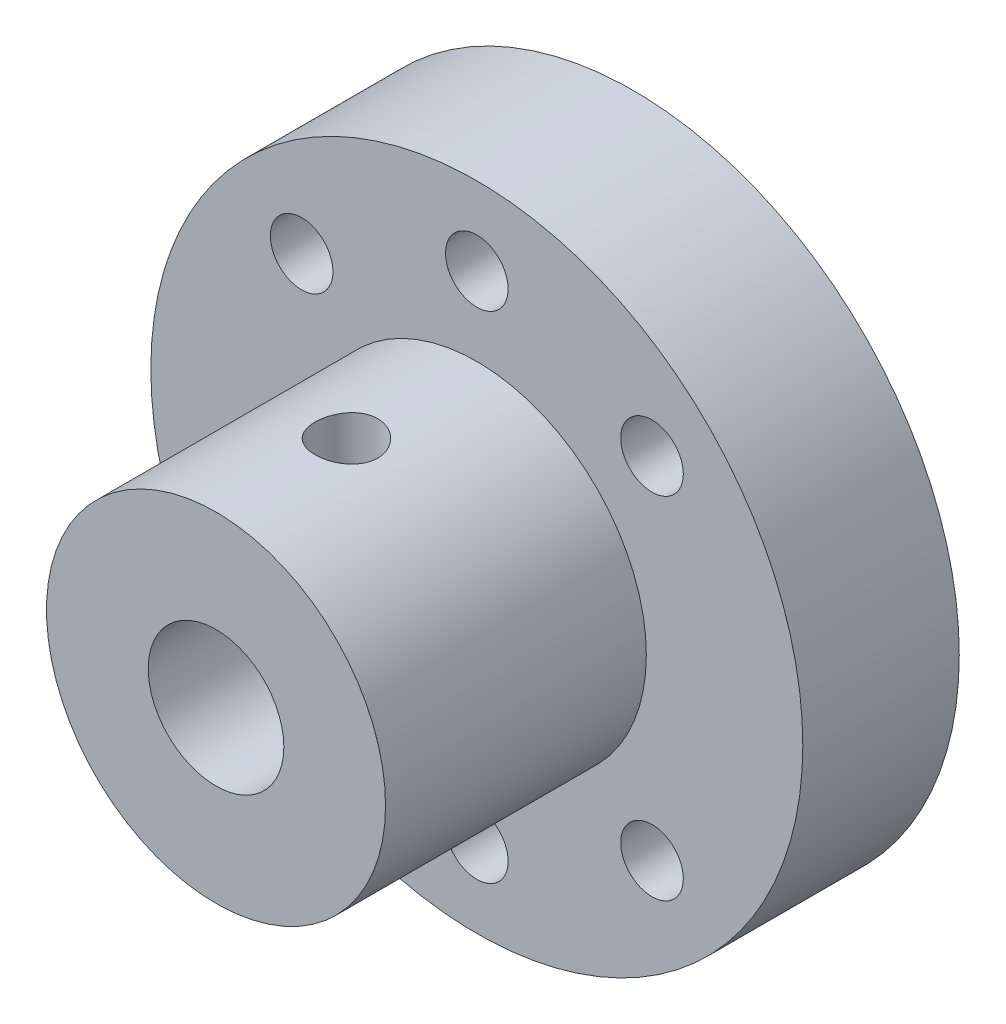
from build123d import *

# Parameters (mm, degrees)
SKETCH2_R               = 12.5
BOSS_EXTRUDE1_DEPTH     = 6
SKETCH3_R               = 6.5
SKETCH3_R_2             = 2.5
BOSS_EXTRUDE2_DEPTH     = 10
CUT_EXTRUDE1_DEPTH      = 25
CUT_EXTRUDE1_DEPTH_BACK = 25
SKETCH4_R               = 1.2
SKETCH5_R               = 1.2
CUT_EXTRUDE2_DEPTH      = 25
CIRPATTERN1_COUNT       = 2
CIRPATTERN1_ANGLE       = 45
CUT_EXTRUDE3_DEPTH      = 50
CUT_EXTRUDE3_DEPTH_BACK = 20
SKETCH6_R               = 2.6
CIRPATTERN2_COUNT       = 2
CIRPATTERN2_ANGLE       = 315
MIRROR1_COPY_1_SKETCH_R = 1.2
MIRROR1_COPY_1_DEPTH    = 25
MIRROR1_COPY_2_SKETCH_R = 1.2
MIRROR1_COPY_2_DEPTH    = 25
MIRROR1_COPY_3_SKETCH_R = 1.2
MIRROR1_COPY_3_DEPTH    = 25
MIRROR1_COPY_4_SKETCH_R = 1.2
MIRROR1_COPY_4_DEPTH    = 25


with BuildPart() as part:
    # Sketch2 → Boss-Extrude1 (new body)
    with BuildSketch(Plane.XY):
        Circle(SKETCH2_R)
    extrude(amount=BOSS_EXTRUDE1_DEPTH)

    # Sketch3 → Boss-Extrude2 (add)
    with BuildSketch(Plane.XY.offset(6)):
        Circle(SKETCH3_R)
        Circle(SKETCH3_R_2, mode=Mode.SUBTRACT)
    extrude(amount=BOSS_EXTRUDE2_DEPTH)

    # Sketch4 → Cut-Extrude1 (cut, two sides: drawn at the far end of the back side and taken through both)
    with BuildSketch(Plane(origin=(0, 0, 0), x_dir=(1, 0, 0), z_dir=(0, 1, 0)).offset(-CUT_EXTRUDE1_DEPTH_BACK)):
        with Locations((0, -11)):
            Circle(SKETCH4_R)
    extrude(amount=CUT_EXTRUDE1_DEPTH + CUT_EXTRUDE1_DEPTH_BACK, mode=Mode.SUBTRACT)

    # Sketch5 → Cut-Extrude2 (cut, symmetric)
    with BuildSketch(Plane.XY.offset(6)):
        with Locations((0, 9.5)):
            Circle(SKETCH5_R)
    cut_extrude2 = extrude(amount=CUT_EXTRUDE2_DEPTH, both=True, mode=Mode.SUBTRACT)

    # CirPattern1: Cut-Extrude2 ×2 about axis
    cirpattern1_axis = Axis((0, 0, -0.6), (0, 0, 1))
    for i in range(1, CIRPATTERN1_COUNT):
        add(cut_extrude2.rotate(cirpattern1_axis, i * CIRPATTERN1_ANGLE / (CIRPATTERN1_COUNT - 1)), mode=Mode.SUBTRACT)

    # Sketch6 → Cut-Extrude3 (cut, two sides: drawn at the far end of the back side and taken through both)
    with BuildSketch(Plane.XY.offset(6).offset(-CUT_EXTRUDE3_DEPTH_BACK)):
        Circle(SKETCH6_R)
    extrude(amount=CUT_EXTRUDE3_DEPTH + CUT_EXTRUDE3_DEPTH_BACK, mode=Mode.SUBTRACT)

    # CirPattern2: Cut-Extrude2 ×2 about axis
    cirpattern2_axis = Axis((0, 0, 6), (0, 0, 1))
    for i in range(1, CIRPATTERN2_COUNT):
        add(cut_extrude2.rotate(cirpattern2_axis, i * CIRPATTERN2_ANGLE / (CIRPATTERN2_COUNT - 1)), mode=Mode.SUBTRACT)

    # Mirror1 copy 1 sketch → Mirror1 copy 1 (cut, symmetric)
    with BuildSketch(Plane(origin=(0, 0, 6), x_dir=(0.707106781186546, -0.707106781186549, 0), z_dir=(0, 0, 1))):
        with Locations((0, -9.5)):
            Circle(MIRROR1_COPY_1_SKETCH_R)
    extrude(amount=MIRROR1_COPY_1_DEPTH, both=True, mode=Mode.SUBTRACT)

    # Mirror1 copy 2 sketch → Mirror1 copy 2 (cut, symmetric)
    with BuildSketch(Plane.XY.offset(6)):
        with Locations((0, -9.5)):
            Circle(MIRROR1_COPY_2_SKETCH_R)
    extrude(amount=MIRROR1_COPY_2_DEPTH, both=True, mode=Mode.SUBTRACT)

    # Mirror1 copy 3 sketch → Mirror1 copy 3 (cut, symmetric)
    with BuildSketch(Plane(origin=(0, 0, 6), x_dir=(0.7071067811865561, 0.7071067811865389, 0), z_dir=(0, 0, 1))):
        with Locations((0, -9.5)):
            Circle(MIRROR1_COPY_3_SKETCH_R)
    extrude(amount=MIRROR1_COPY_3_DEPTH, both=True, mode=Mode.SUBTRACT)

    # Mirror1 copy 4 sketch → Mirror1 copy 4 (cut, symmetric)
    with BuildSketch(Plane.XY.offset(6)):
        with Locations((0, -9.5)):
            Circle(MIRROR1_COPY_4_SKETCH_R)
    extrude(amount=MIRROR1_COPY_4_DEPTH, both=True, mode=Mode.SUBTRACT)


solid = part.part
